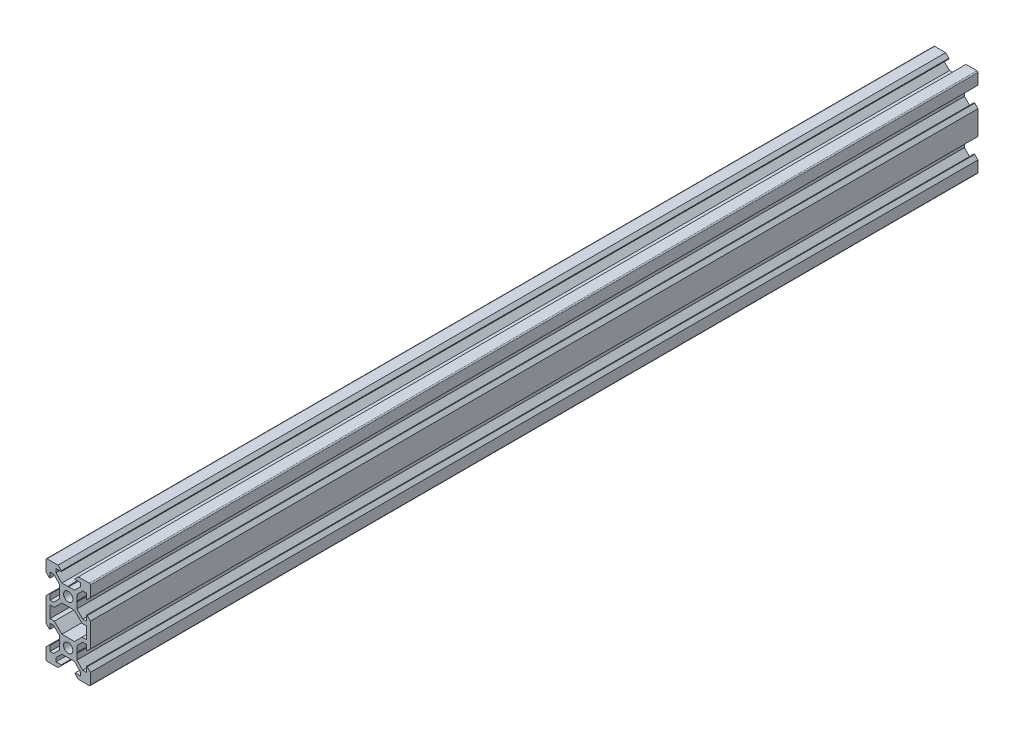
from build123d import *

# Parameters (mm, degrees)
SKETCH1_R           = 2.1
BOSS_EXTRUDE1_DEPTH = 400


with BuildPart() as part:
    # Sketch1 → Boss-Extrude1 (new body)
    with BuildSketch(Plane.XY):
        with BuildLine():
            Line((4.58, -20), (9.5, -20))
            ThreePointArc((9.5, -20), (9.853553391, -19.853553391), (10, -19.5))
            Line((10, -19.5), (10, -14.58))
            Line((10, -14.58), (8.545, -13.125))
            Line((8.545, -13.125), (8.2, -13.125))
            Line((8.2, -13.125), (8.2, -15.5))
            Line((8.2, -15.5), (6.560660172, -15.5))
            Line((6.560660172, -15.5), (3.9, -12.839339828))
            Line((3.9, -12.839339828), (3.9, -10.21))
            Line((3.9, -10.21), (3.69, -10))
            Line((3.69, -10), (3.9, -9.79))
            Line((3.9, -9.79), (3.9, -7.160660172))
            Line((3.9, -7.160660172), (6.560660172, -4.5))
            Line((6.560660172, -4.5), (8.2, -4.5))
            Line((8.2, -4.5), (8.2, -6.875))
            Line((8.2, -6.875), (8.545, -6.875))
            Line((8.545, -6.875), (10, -5.42))
            Line((10, -5.42), (10, 5.42))
            Line((10, 5.42), (8.545, 6.875))
            Line((8.545, 6.875), (8.2, 6.875))
            Line((8.2, 6.875), (8.2, 4.5))
            Line((8.2, 4.5), (6.560660172, 4.5))
            Line((6.560660172, 4.5), (3.9, 7.160660172))
            Line((3.9, 7.160660172), (3.9, 9.79))
            Line((3.9, 9.79), (3.69, 10))
            Line((3.69, 10), (3.9, 10.21))
            Line((3.9, 10.21), (3.9, 12.839339828))
            Line((3.9, 12.839339828), (6.560660172, 15.5))
            Line((6.560660172, 15.5), (8.2, 15.5))
            Line((8.2, 15.5), (8.2, 13.125))
            Line((8.2, 13.125), (8.545, 13.125))
            Line((8.545, 13.125), (10, 14.58))
            Line((10, 14.58), (10, 19.5))
            ThreePointArc((10, 19.5), (9.853553391, 19.853553391), (9.5, 20))
            Line((9.5, 20), (4.58, 20))
            Line((4.58, 20), (3.125, 18.545))
            Line((3.125, 18.545), (3.125, 18.2))
            Line((3.125, 18.2), (5.5, 18.2))
            Line((5.5, 18.2), (5.5, 16.560660172))
            Line((5.5, 16.560660172), (2.839339828, 13.9))
            Line((2.839339828, 13.9), (0.21, 13.9))
            Line((0.21, 13.9), (0, 13.69))
            Line((0, 13.69), (-0.21, 13.9))
            Line((-0.21, 13.9), (-2.839339828, 13.9))
            Line((-2.839339828, 13.9), (-5.5, 16.560660172))
            Line((-5.5, 16.560660172), (-5.5, 18.2))
            Line((-5.5, 18.2), (-3.125, 18.2))
            Line((-3.125, 18.2), (-3.125, 18.545))
            Line((-3.125, 18.545), (-4.58, 20))
            Line((-4.58, 20), (-9.5, 20))
            ThreePointArc((-9.5, 20), (-9.853553391, 19.853553391), (-10, 19.5))
            Line((-10, 19.5), (-10, 14.58))
            Line((-10, 14.58), (-8.545, 13.125))
            Line((-8.545, 13.125), (-8.2, 13.125))
            Line((-8.2, 13.125), (-8.2, 15.5))
            Line((-8.2, 15.5), (-6.560660172, 15.5))
            Line((-6.560660172, 15.5), (-3.9, 12.839339828))
            Line((-3.9, 12.839339828), (-3.9, 10.21))
            Line((-3.9, 10.21), (-3.69, 10))
            Line((-3.69, 10), (-3.9, 9.79))
            Line((-3.9, 9.79), (-3.9, 7.160660172))
            Line((-3.9, 7.160660172), (-6.560660172, 4.5))
            Line((-6.560660172, 4.5), (-8.2, 4.5))
            Line((-8.2, 4.5), (-8.2, 6.875))
            Line((-8.2, 6.875), (-8.545, 6.875))
            Line((-8.545, 6.875), (-10, 5.42))
            Line((-10, 5.42), (-10, -5.42))
            Line((-10, -5.42), (-8.545, -6.875))
            Line((-8.545, -6.875), (-8.2, -6.875))
            Line((-8.2, -6.875), (-8.2, -4.5))
            Line((-8.2, -4.5), (-6.560660172, -4.5))
            Line((-6.560660172, -4.5), (-3.9, -7.160660172))
            Line((-3.9, -7.160660172), (-3.9, -9.79))
            Line((-3.9, -9.79), (-3.69, -10))
            Line((-3.69, -10), (-3.9, -10.21))
            Line((-3.9, -10.21), (-3.9, -12.839339828))
            Line((-3.9, -12.839339828), (-6.560660172, -15.5))
            Line((-6.560660172, -15.5), (-8.2, -15.5))
            Line((-8.2, -15.5), (-8.2, -13.125))
            Line((-8.2, -13.125), (-8.545, -13.125))
            Line((-8.545, -13.125), (-10, -14.58))
            Line((-10, -14.58), (-10, -19.5))
            ThreePointArc((-10, -19.5), (-9.853553391, -19.853553391), (-9.5, -20))
            Line((-9.5, -20), (-4.58, -20))
            Line((-4.58, -20), (-3.125, -18.545))
            Line((-3.125, -18.545), (-3.125, -18.2))
            Line((-3.125, -18.2), (-5.5, -18.2))
            Line((-5.5, -18.2), (-5.5, -16.560660172))
            Line((-5.5, -16.560660172), (-2.839339828, -13.9))
            Line((-2.839339828, -13.9), (-0.21, -13.9))
            Line((-0.21, -13.9), (0, -13.69))
            Line((0, -13.69), (0.21, -13.9))
            Line((0.21, -13.9), (2.839339828, -13.9))
            Line((2.839339828, -13.9), (5.5, -16.560660172))
            Line((5.5, -16.560660172), (5.5, -18.2))
            Line((5.5, -18.2), (3.125, -18.2))
            Line((3.125, -18.2), (3.125, -18.545))
            Line((3.125, -18.545), (4.58, -20))
        make_face()
        with Locations((0, -10)):
            Circle(SKETCH1_R, mode=Mode.SUBTRACT)
        Polygon((-6.239339828, -2.7), (-8.2, -2.7), (-8.2, 2.7), (-6.239339828, 2.7), (-2.839339828, 6.1), (2.839339828, 6.1), (6.239339828, 2.7), (8.2, 2.7), (8.2, -2.7), (6.239339828, -2.7), (2.839339828, -6.1), (-2.839339828, -6.1), align=None, mode=Mode.SUBTRACT)
        with Locations((0, 10)):
            Circle(SKETCH1_R, mode=Mode.SUBTRACT)
    extrude(amount=BOSS_EXTRUDE1_DEPTH)


solid = part.part
